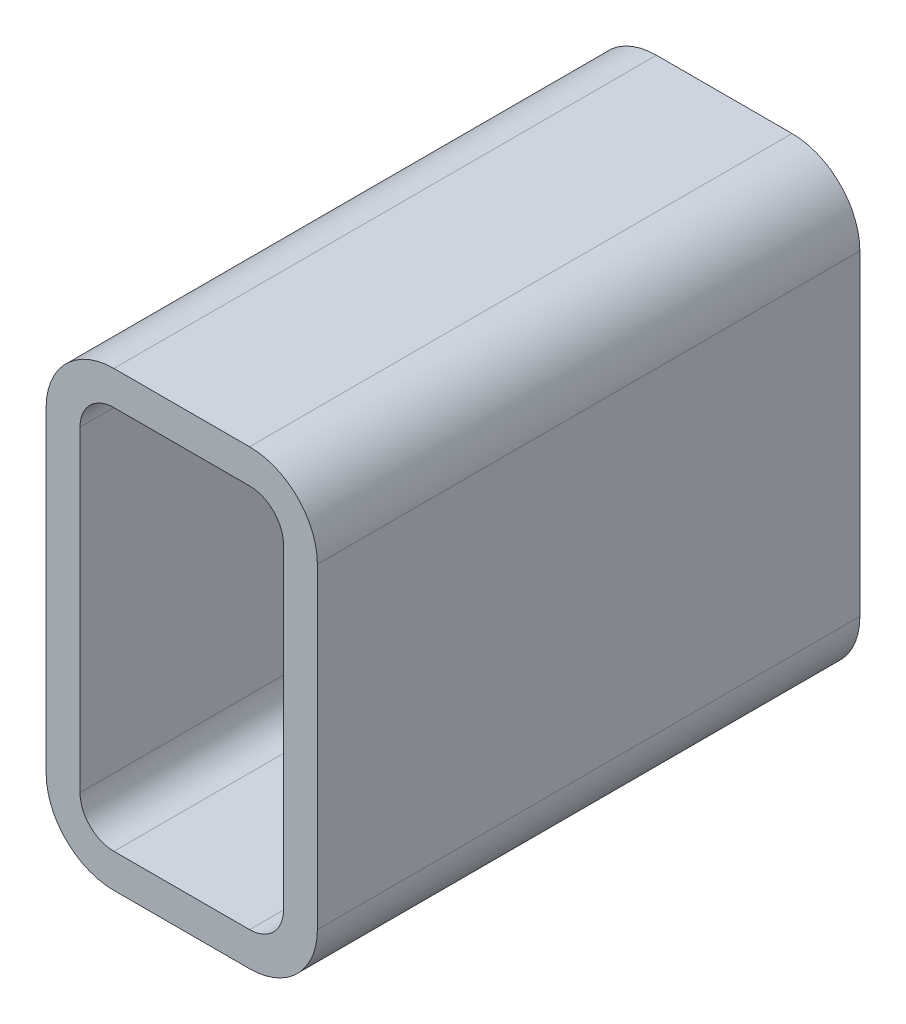
from build123d import *

# Parameters (mm, degrees)
BASETUBER_DEPTH    = 76.2
CUT_EXTRUDE1_REACH = 78.2
SKETCH2_R          = 9.525


with BuildPart() as part:
    # Sketch1 → BaseTubeR (new body, symmetric)
    with BuildSketch(Plane.XY):
        with BuildLine():
            Line((19.05, 0), (57.15, 0))
            ThreePointArc((57.15, 0), (70.620384182, 5.579615818), (76.2, 19.05))
            Line((76.2, 19.05), (76.2, 107.95))
            ThreePointArc((76.2, 107.95), (70.620384182, 121.420384182), (57.15, 127))
            Line((57.15, 127), (19.05, 127))
            ThreePointArc((19.05, 127), (5.579615818, 121.420384182), (0, 107.95))
            Line((0, 107.95), (0, 19.05))
            ThreePointArc((0, 19.05), (5.579615818, 5.579615818), (19.05, 0))
        make_face()
        with BuildLine():
            Line((19.05, 9.525), (57.15, 9.525))
            ThreePointArc((57.15, 9.525), (63.885192091, 12.314807909), (66.675, 19.05))
            Line((66.675, 19.05), (66.675, 107.95))
            ThreePointArc((66.675, 107.95), (63.885192091, 114.685192091), (57.15, 117.475))
            Line((57.15, 117.475), (19.05, 117.475))
            ThreePointArc((19.05, 117.475), (12.314807909, 114.685192091), (9.525, 107.95))
            Line((9.525, 107.95), (9.525, 19.05))
            ThreePointArc((9.525, 19.05), (12.314807909, 12.314807909), (19.05, 9.525))
        make_face(mode=Mode.SUBTRACT)
    extrude(amount=BASETUBER_DEPTH, both=True)

    # Sketch2 → Cut-Extrude1 (cut, up to next)
    with BuildSketch(Plane.ZY, mode=Mode.PRIVATE) as cut_extrude1_sk1:
        with Locations((-38.1, 31.75)):
            Circle(SKETCH2_R)
    cut_extrude1_tool1 = extrude(cut_extrude1_sk1.sketch, amount=-CUT_EXTRUDE1_REACH, mode=Mode.PRIVATE) & part.part
    add(cut_extrude1_tool1.solids().sort_by_distance((0, 31.75, -38.1))[0], mode=Mode.SUBTRACT)


solid = part.part
